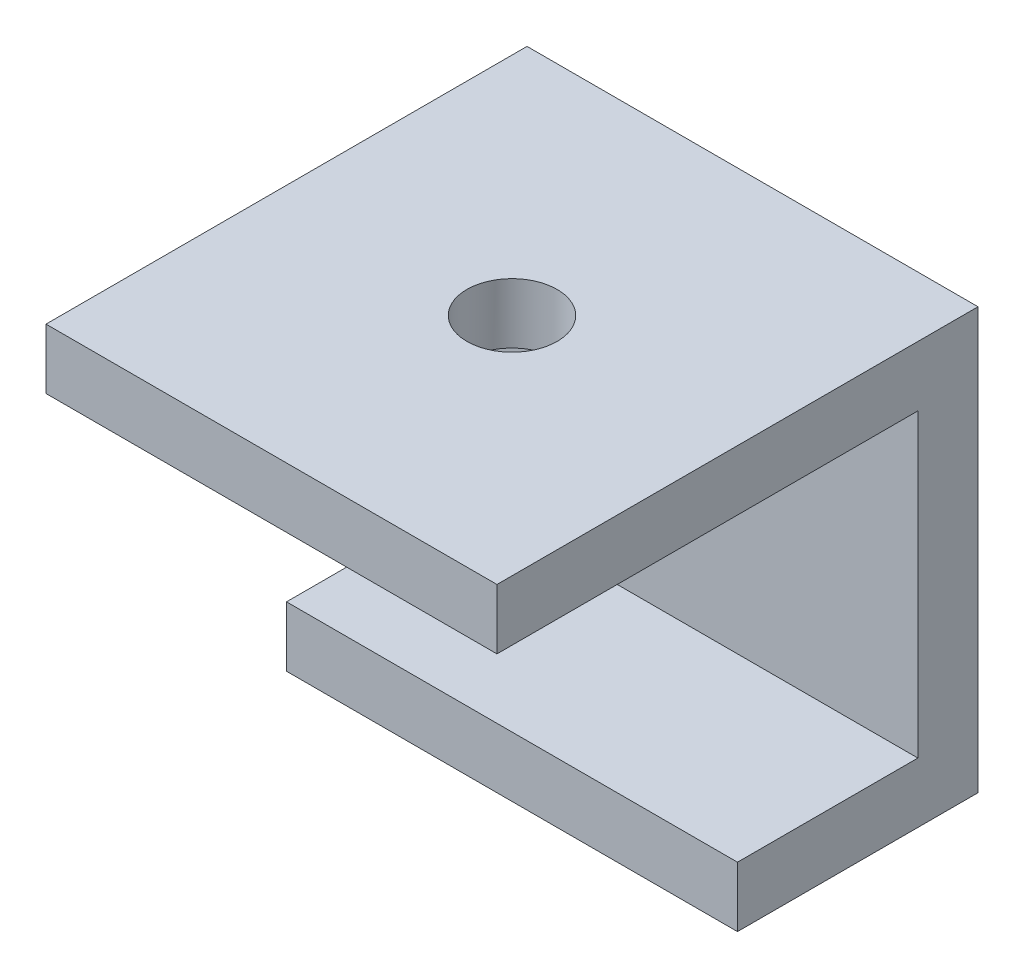
from build123d import *

# Parameters (mm, degrees)
BOSS_EXTRUDE1_DEPTH = 15
CUT_EXTRUDE1_REACH  = 16
SKETCH2_R           = 1.5


with BuildPart() as part:
    # Sketch1 → Boss-Extrude1 (new body)
    with BuildSketch(Plane(origin=(0, 0, 0), x_dir=(0, 0, -1), z_dir=(1, 0, 0))):
        Polygon((0, 0), (0, -14), (-8, -14), (-8, -12), (-2, -12), (-2, -2), (-16, -2), (-16, 0), align=None)
    extrude(amount=-BOSS_EXTRUDE1_DEPTH)

    # Sketch2 → Cut-Extrude1 (cut, up to next)
    with BuildSketch(Plane(origin=(0, 0, 0), x_dir=(1, 0, 0), z_dir=(0, 1, 0)), mode=Mode.PRIVATE) as cut_extrude1_sk1:
        with Locations((-7.5, -8)):
            Circle(SKETCH2_R)
    cut_extrude1_tool1 = extrude(cut_extrude1_sk1.sketch, amount=-CUT_EXTRUDE1_REACH, mode=Mode.PRIVATE) & part.part
    add(cut_extrude1_tool1.solids().sort_by_distance((-7.5, 0, 8))[0], mode=Mode.SUBTRACT)


solid = part.part
